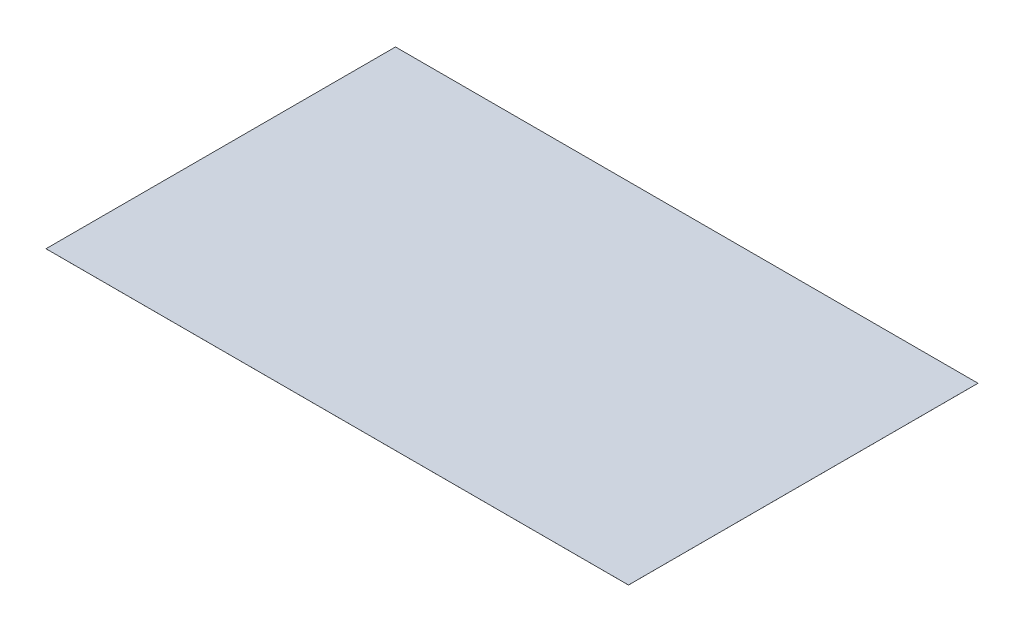
from build123d import *

# Parameters (mm, degrees)
ESQUISSE1_W        = 25000
ESQUISSE1_H        = 15000
BOSS_EXTRU_1_DEPTH = 1


with BuildPart() as part:
    # Esquisse1 → Boss.-Extru.1 (new body)
    with BuildSketch(Plane(origin=(0, 0, 0), x_dir=(1, 0, 0), z_dir=(0, 1, 0))):
        Rectangle(ESQUISSE1_W, ESQUISSE1_H)
    extrude(amount=BOSS_EXTRU_1_DEPTH)


solid = part.part
